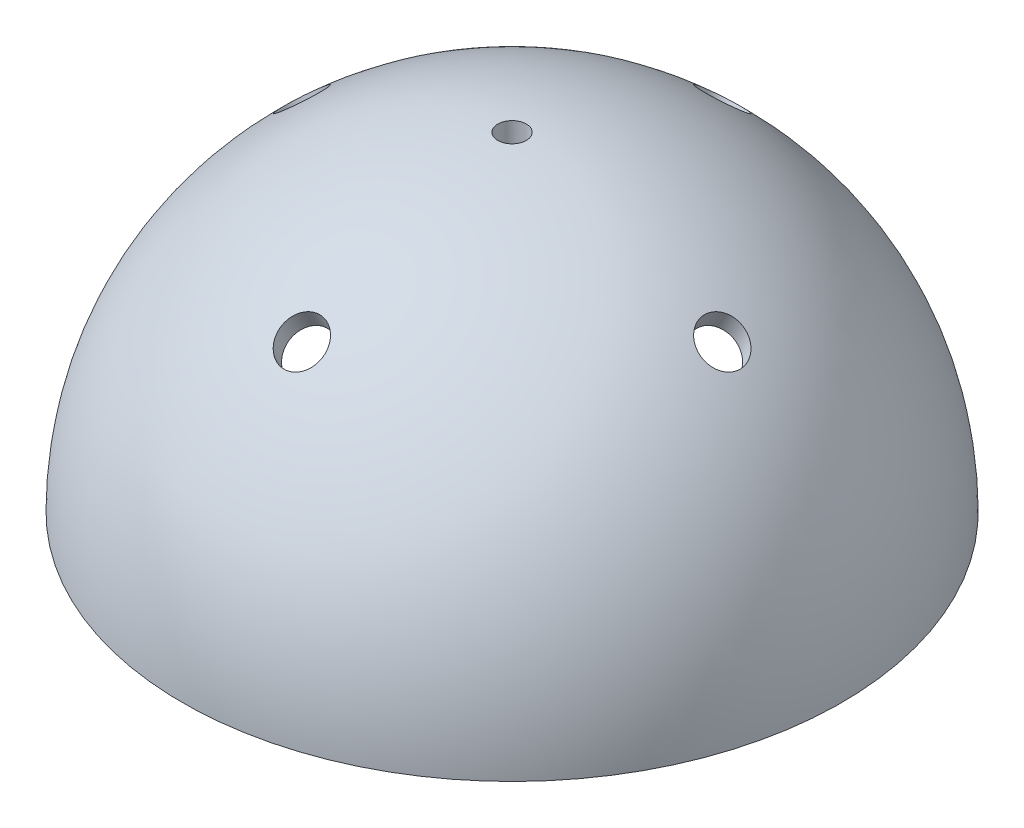
from build123d import *

# Parameters (mm, degrees)
CIRPATTERN1_COUNT = 4


with BuildPart() as part:
    # Sketch1 → Revolve2 (revolve)
    with BuildSketch(Plane.XY):
        with BuildLine():
            Line((0, 0), (0, 40.291803418))
            ThreePointArc((0, 40.291803418), (-28.490607423, 28.490607423), (-40.291803418, 0))
            Line((-40.291803418, 0), (0, 0))
        make_face()
    revolve(axis=Axis((0, 0, 0), (0, 1, 0)))

    # Sketch3 → Cut-Revolve1 (revolve, cut)
    with BuildSketch(Plane.XY):
        Polygon((-13.573190225, 7.131738402), (-11.349241682, 8.238626263), (-25.928069212, 37.530267603), (-29.089104454, 37.530267603), align=None)
    cut_revolve1 = revolve(axis=Axis((-13.573190225, 7.131738402, 0), (-0.4546205334501406, 0.8906852252987638, 0)), mode=Mode.SUBTRACT)

    # CirPattern1: Cut-Revolve1 ×4 about axis
    cirpattern1_axis = Axis((0, 42.306393589, 0), (0, -1, 0))
    for i in range(1, CIRPATTERN1_COUNT):
        add(cut_revolve1.rotate(cirpattern1_axis, i * 360 / CIRPATTERN1_COUNT), mode=Mode.SUBTRACT)

    # Sketch4 → Cut-Revolve2 (revolve, cut)
    with BuildSketch(Plane.XY):
        with BuildLine():
            Line((-38.362655309, 0), (-6.620258084, 0))
            Line((-6.620258084, 0), (-6.620258084, 0.892081856))
            Line((-6.620258084, 0.892081856), (-6.620258084, 3.681873627))
            Line((-6.620258084, 3.681873627), (-6.620258084, 4.5102659))
            Line((-6.620258084, 4.5102659), (-6.620258084, 8.647730458))
            Line((-6.620258084, 8.647730458), (-6.620258084, 37.476063899))
            ThreePointArc((-6.620258084, 37.476063899), (-29.313593387, 24.516412874), (-38.362655309, 0))
        make_face()
    revolve(axis=Axis((0, 0, 0), (0, 1, 0)), mode=Mode.SUBTRACT)

    # Sketch5 → Cut-Revolve3 (revolve, cut)
    with BuildSketch(Plane.XY):
        Polygon((0, 0), (0, 48.293152638), (1.742012272, 48.293152638), (1.742012272, -4.609009531), (0, -4.609009531), align=None)
    revolve(axis=Axis((0, 42.306393589, 0), (0, -1, 0)), mode=Mode.SUBTRACT)


solid = part.part
